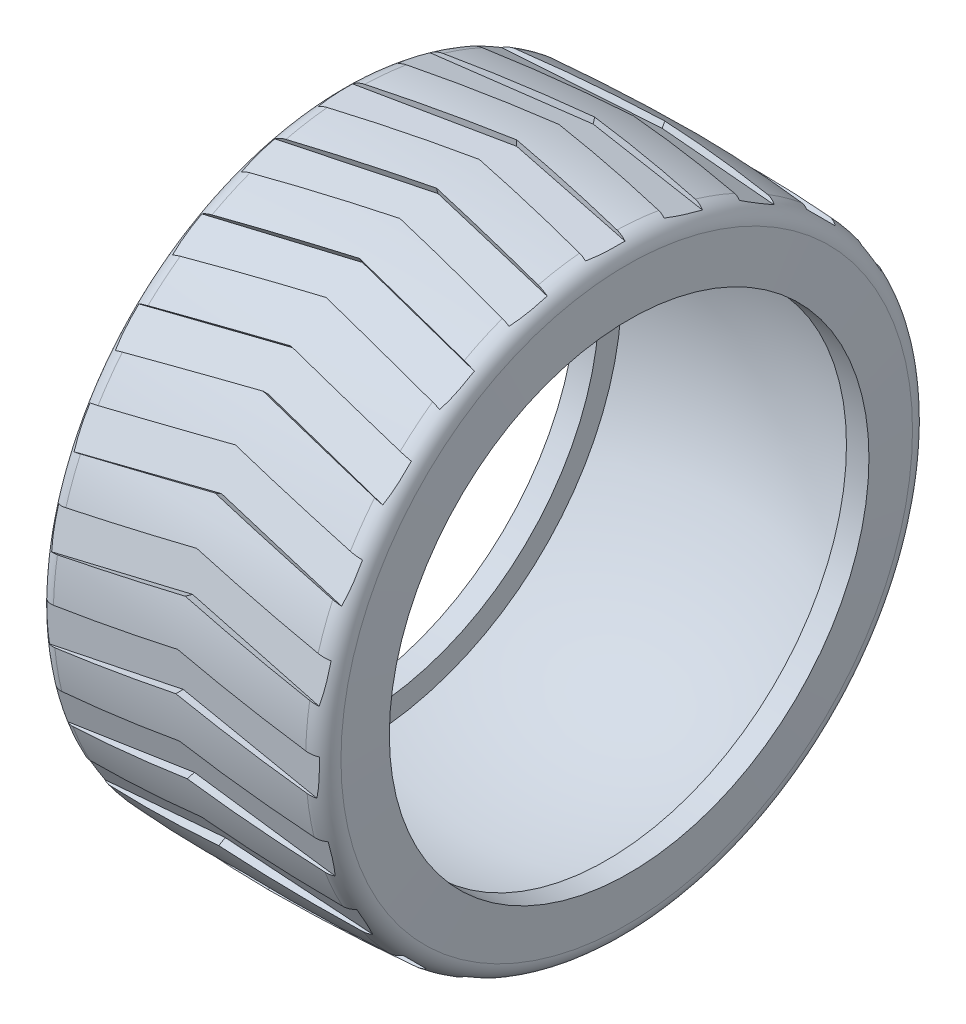
from build123d import *

# Parameters (mm, degrees)
SCHNITT_LINEAR_AUSTRAGEN2_DEPTH = 1
KREISMUSTER6_COUNT              = 24


with BuildPart() as part:
    # Skizze2 → Rotation1 (revolve)
    with BuildSketch(Plane.XY):
        with BuildLine():
            Line((-16.5, 35), (-16.5, 32))
            Line((-16.5, 32), (-19.5, 32))
            Line((-19.5, 32), (-19.5, 41))
            Line((-19.5, 41), (19.5, 41))
            Line((19.5, 41), (19.5, 32))
            Line((19.5, 32), (16.5, 32))
            Line((16.5, 32), (16.5, 35))
            ThreePointArc((16.5, 35), (0, 37.5), (-16.5, 35))
        make_face()
    revolve(axis=Axis((0, 0, 0), (1, 0, 0)))

    # Skizze3 → Schnitt-Linear austragen2 (cut)
    with BuildSketch(Plane.XY.offset(41)):
        Polygon((-19.5, 0.5), (0, 4.5), (19.5, 0.5), (19.5, -4.5), (0, -0.5), (-19.5, -4.5), align=None)
    schnitt_linear_austragen2 = extrude(amount=-SCHNITT_LINEAR_AUSTRAGEN2_DEPTH, mode=Mode.SUBTRACT)

    # Kreismuster6: Schnitt-Linear austragen2 ×24 about axis
    kreismuster6_axis = Axis((-20.3527775, 0, 0), (1, 0, 0))
    for i in range(1, KREISMUSTER6_COUNT):
        add(schnitt_linear_austragen2.rotate(kreismuster6_axis, i * 360 / KREISMUSTER6_COUNT), mode=Mode.SUBTRACT)

    # Skizze4 → Schnitt-Rotation5 (revolve, cut)
    with BuildSketch(Plane.XY):
        with BuildLine():
            Line((-19.178625019, 38.132199944), (-19.5, 32))
            Line((-19.5, 32), (-20.5, 32))
            Line((-20.5, 32), (-20.5, 41.996951106))
            Line((-20.5, 41.996951106), (20.5, 41.996951106))
            Line((20.5, 41.996951106), (20.5, 32))
            Line((20.5, 32), (19.5, 32))
            Line((19.5, 32), (19.178625019, 38.132199944))
            ThreePointArc((19.178625019, 38.132199944), (18.456028594, 39.762894651), (16.830460403, 40.496951106))
            ThreePointArc((16.830460403, 40.496951106), (0, 40.996951106), (-16.830460403, 40.496951106))
            ThreePointArc((-16.830460403, 40.496951106), (-18.456028594, 39.762894651), (-19.178625019, 38.132199944))
        make_face()
    revolve(axis=Axis((-18.5, 0, 0), (1, 0, 0)), mode=Mode.SUBTRACT)


solid = part.part
